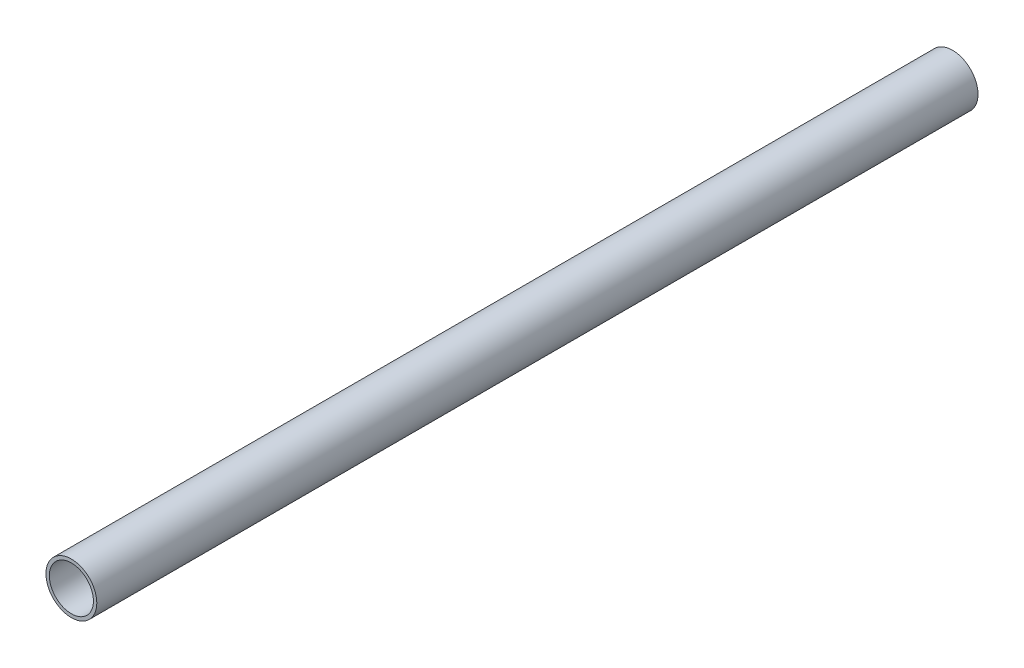
from build123d import *

# Parameters (mm, degrees)
SKETCH1_R           = 9.525
SKETCH1_R_2         = 8.255
BOSS_EXTRUDE1_DEPTH = 330.2


with BuildPart() as part:
    # Sketch1 → Boss-Extrude1 (new body)
    with BuildSketch(Plane.XY):
        Circle(SKETCH1_R)
        Circle(SKETCH1_R_2, mode=Mode.SUBTRACT)
    extrude(amount=BOSS_EXTRUDE1_DEPTH)


solid = part.part
